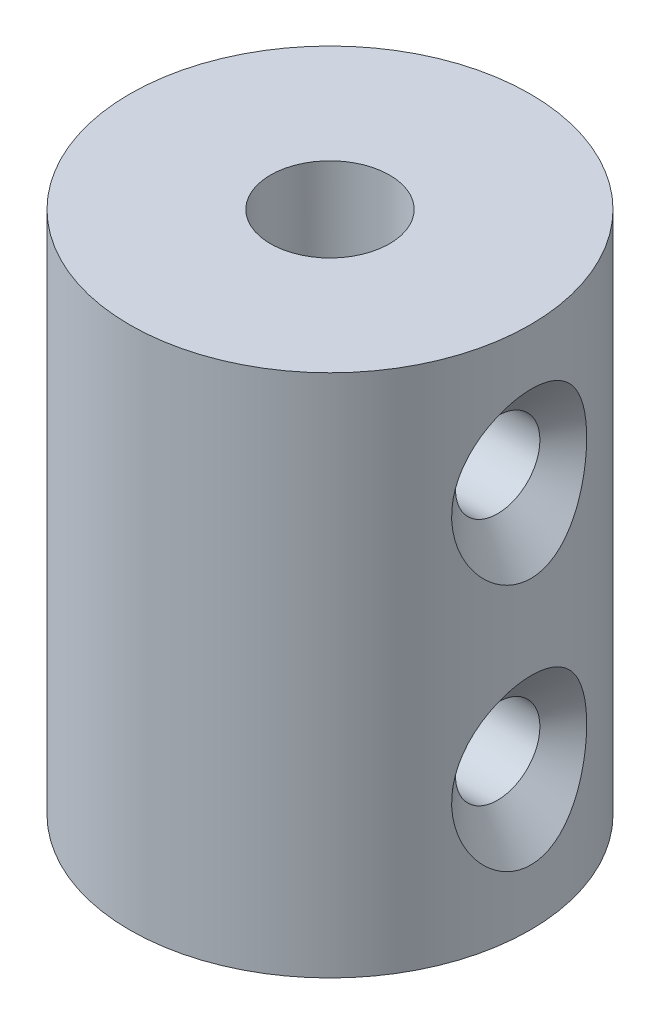
from build123d import *

# Parameters (mm, degrees)
SKETCH1_R           = 5.334
BOSS_EXTRUDE1_DEPTH = 13.97
SKETCH2_R           = 1.5875
CUT_EXTRUDE1_DEPTH  = 14.97


with BuildPart() as part:
    # Sketch1 → Boss-Extrude1 (new body)
    with BuildSketch(Plane(origin=(0, 0, 0), x_dir=(1, 0, 0), z_dir=(0, 1, 0))):
        Circle(SKETCH1_R)
    extrude(amount=BOSS_EXTRUDE1_DEPTH)

    # Sketch2 → Cut-Extrude1 (cut, through all)
    with BuildSketch(Plane(origin=(0, 0, 0), x_dir=(-1, 0, 0), z_dir=(0, -1, 0))):
        Circle(SKETCH2_R)
    extrude(amount=-CUT_EXTRUDE1_DEPTH, mode=Mode.SUBTRACT)

    # Sketch6 → CSK for #2 Flat Head Machine Screw (100)2 (revolve, cut)
    with BuildSketch(Plane(origin=(5.33394419, 3.679102393, -0.024400355), x_dir=(-0.004574495, 0, -0.999989537), z_dir=(0, 1, 0))):
        Polygon((0, 0), (0, 7.537152758), (1.1303, 6.858), (1.1303, 0.884494921), (2.1844, 0), align=None)
    csk_for_2_flat_head_machine_screw_100 = revolve(axis=Axis((11.68387775, 3.679102393, -0.053448397), (-0.999989537, 0, 0.004574495)), mode=Mode.SUBTRACT)

    # Mirror3: CSK for #2 Flat Head Machine Screw (100)2 across plane
    add(csk_for_2_flat_head_machine_screw_100.mirror(Plane(origin=(0, 6.985, 0), x_dir=(0, 0, 1), z_dir=(0, -1, 0))), mode=Mode.SUBTRACT)


solid = part.part
